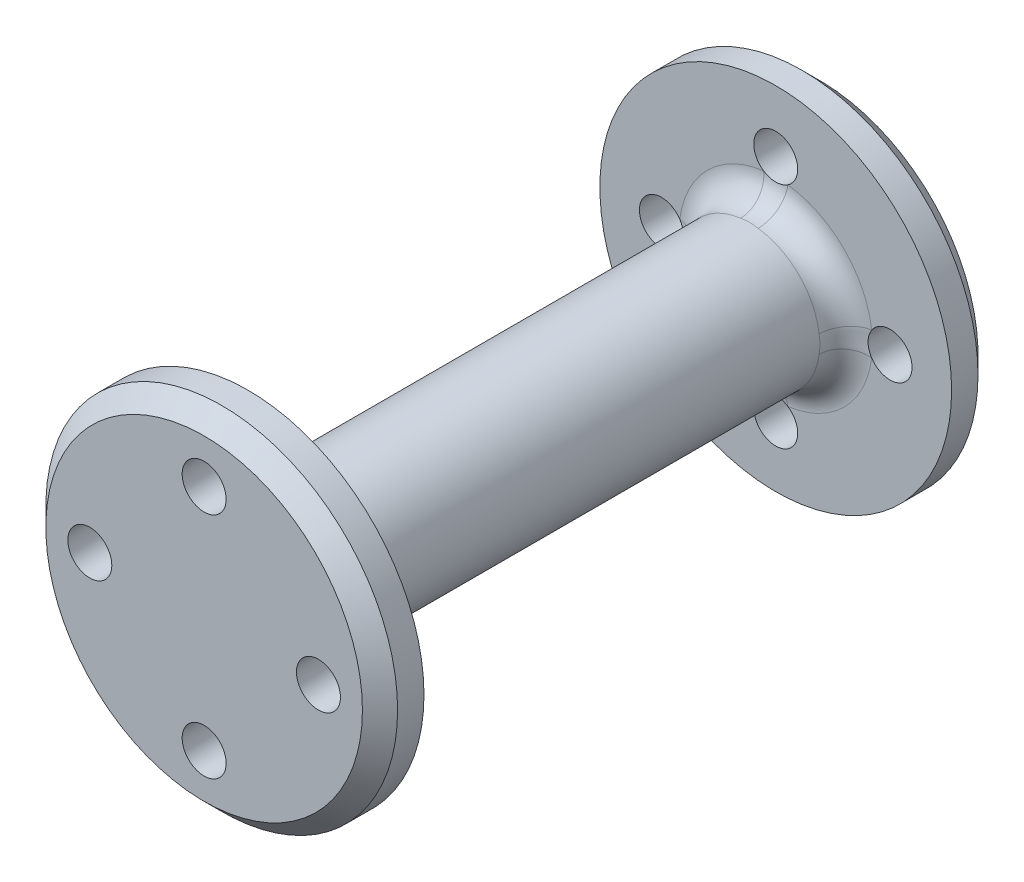
from build123d import *

# Parameters (mm, degrees)
SKETCH1_R                = 8
BOSS_EXTRUDE1_DEPTH      = 30
SKETCH2_R                = 20
BOSS_EXTRUDE2_DEPTH      = 5
CHAMFER1_SIZE            = 2
SKETCH3_R                = 2.5
CUT_EXTRUDE1_DEPTH       = 71.887234394
CIRPATTERN1_COUNT        = 4
FILLET1_R                = 3
MIRROR5_COPY_1_SKETCH_R  = 2.5
MIRROR5_COPY_1_DEPTH     = 71.887234394
MIRROR5_COPY_2_SKETCH_R  = 2.5
MIRROR5_COPY_2_DEPTH     = 71.887234394
MIRROR5_COPY_3_SKETCH_R  = 2.5
MIRROR5_COPY_3_DEPTH     = 71.887234394
CHAMFER1_OF_MIRROR5_SIZE = 2
FILLET1_OF_MIRROR5_R     = 3


with BuildPart() as part:
    # Sketch1 → Boss-Extrude1 (new, symmetric)
    with BuildSketch(Plane.XY):
        Circle(SKETCH1_R)
    extrude(amount=BOSS_EXTRUDE1_DEPTH, both=True)

    # Sketch2 → Boss-Extrude2 (add)
    with BuildSketch(Plane.XY.offset(30)):
        Circle(SKETCH2_R)
    boss_extrude2 = extrude(amount=BOSS_EXTRUDE2_DEPTH)

    # Chamfer1
    chamfer1_edges = [part.edges().sort_by_distance(p)[0] for p in [
        (-20, 0, 35),
    ]]
    chamfer(chamfer1_edges, length=CHAMFER1_SIZE)

    # Sketch3 → Cut-Extrude1 (cut, through all)
    with BuildSketch(Plane.XY.offset(35)):
        with Locations((0, 13)):
            Circle(SKETCH3_R)
    cut_extrude1 = extrude(amount=-CUT_EXTRUDE1_DEPTH, mode=Mode.SUBTRACT)

    # CirPattern1: Cut-Extrude1 ×4 about axis
    cirpattern1_axis = Axis((0, 0, 0), (0, 0, 1))
    for i in range(1, CIRPATTERN1_COUNT):
        add(cut_extrude1.rotate(cirpattern1_axis, i * 360 / CIRPATTERN1_COUNT), mode=Mode.SUBTRACT)

    # Fillet1
    fillet1_edges = [part.edges().sort_by_distance(p)[0] for p in [
        (-8, 0, 30),
    ]]
    fillet(fillet1_edges, radius=FILLET1_R)

    # Mirror5: Boss-Extrude2, Cut-Extrude1 across plane
    add(boss_extrude2.mirror(Plane.XY))
    add(cut_extrude1.mirror(Plane.XY), mode=Mode.SUBTRACT)

    # Mirror5 copy 1 sketch → Mirror5 copy 1 (cut, through all)
    with BuildSketch(Plane.YX.offset(35)):
        with Locations((0, -13)):
            Circle(MIRROR5_COPY_1_SKETCH_R)
    extrude(amount=-MIRROR5_COPY_1_DEPTH, mode=Mode.SUBTRACT)

    # Mirror5 copy 2 sketch → Mirror5 copy 2 (cut, through all)
    with BuildSketch(Plane(origin=(0, 0, -35), x_dir=(-1, 0, 0), z_dir=(0, 0, -1))):
        with Locations((0, -13)):
            Circle(MIRROR5_COPY_2_SKETCH_R)
    extrude(amount=-MIRROR5_COPY_2_DEPTH, mode=Mode.SUBTRACT)

    # Mirror5 copy 3 sketch → Mirror5 copy 3 (cut, through all)
    with BuildSketch(Plane(origin=(0, 0, -35), x_dir=(0, -1, 0), z_dir=(0, 0, -1))):
        with Locations((0, -13)):
            Circle(MIRROR5_COPY_3_SKETCH_R)
    extrude(amount=-MIRROR5_COPY_3_DEPTH, mode=Mode.SUBTRACT)

    # Chamfer1 of Mirror5
    chamfer1_of_mirror5_edges = [part.edges().sort_by_distance(p)[0] for p in [
        (-20, 0, -35),
    ]]
    chamfer(chamfer1_of_mirror5_edges, length=CHAMFER1_OF_MIRROR5_SIZE)

    # Fillet1 of Mirror5
    fillet1_of_mirror5_edges = [part.edges().sort_by_distance(p)[0] for p in [
        (-8, 0, -30),
    ]]
    fillet(fillet1_of_mirror5_edges, radius=FILLET1_OF_MIRROR5_R)


solid = part.part
